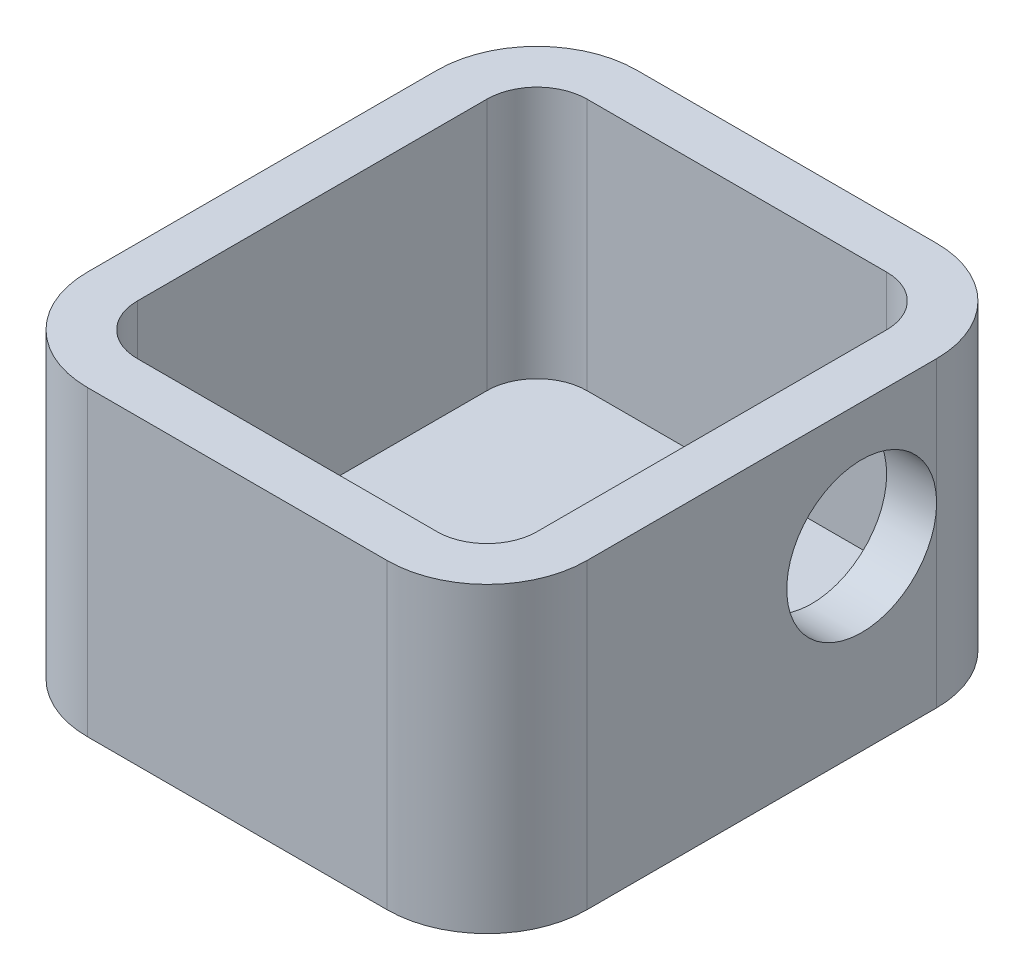
from build123d import *

# Parameters (mm, degrees)
BOSS_EXTRUDE1_DEPTH = 10.11
SKETCH1_3_R         = 4
BOSS_EXTRUDE2_DEPTH = 2
CUT_EXTRUDE1_REACH  = 22
SKETCH3_R           = 3


with BuildPart() as part:
    # Sketch1 → Boss-Extrude1 (new body)
    with BuildSketch(Plane.XZ.offset(5.655564884)):
        with BuildLine():
            Line((-3.830791813, -12.996740626), (-3.830791813, 1.003259374))
            ThreePointArc((-3.830791813, 1.003259374), (-5.002364688, 3.831686499), (-7.830791813, 5.003259374))
            Line((-7.830791813, 5.003259374), (-19.830791813, 5.003259374))
            ThreePointArc((-19.830791813, 5.003259374), (-22.659218938, 3.831686499), (-23.830791813, 1.003259374))
            Line((-23.830791813, 1.003259374), (-23.830791813, -12.996740626))
            ThreePointArc((-23.830791813, -12.996740626), (-22.659218938, -15.825167751), (-19.830791813, -16.996740626))
            Line((-19.830791813, -16.996740626), (-7.830791813, -16.996740626))
            ThreePointArc((-7.830791813, -16.996740626), (-5.002364688, -15.825167751), (-3.830791813, -12.996740626))
        make_face()
        with BuildLine():
            ThreePointArc((-21.830791813, -12.996740626), (-21.245005376, -14.410954188), (-19.830791813, -14.996740626))
            Line((-19.830791813, -14.996740626), (-7.830791813, -14.996740626))
            ThreePointArc((-7.830791813, -14.996740626), (-6.416578251, -14.410954188), (-5.830791813, -12.996740626))
            Line((-5.830791813, -12.996740626), (-5.830791813, 1.003259374))
            ThreePointArc((-5.830791813, 1.003259374), (-6.416578251, 2.417472937), (-7.830791813, 3.003259374))
            Line((-7.830791813, 3.003259374), (-19.830791813, 3.003259374))
            ThreePointArc((-19.830791813, 3.003259374), (-21.245005376, 2.417472937), (-21.830791813, 1.003259374))
            Line((-21.830791813, 1.003259374), (-21.830791813, -12.996740626))
        make_face(mode=Mode.SUBTRACT)
    extrude(amount=-BOSS_EXTRUDE1_DEPTH)

    # Sketch1_3 → Boss-Extrude2 (add)
    with BuildSketch(Plane.XZ.offset(5.655564884)):
        with BuildLine():
            Line((-7.830791813, 5.003259374), (-19.830791813, 5.003259374))
            ThreePointArc((-19.830791813, 5.003259374), (-22.659218938, 3.831686499), (-23.830791813, 1.003259374))
            Line((-23.830791813, 1.003259374), (-23.830791813, -12.996740626))
            ThreePointArc((-23.830791813, -12.996740626), (-22.659218938, -15.825167751), (-19.830791813, -16.996740626))
            Line((-19.830791813, -16.996740626), (-7.830791813, -16.996740626))
            ThreePointArc((-7.830791813, -16.996740626), (-5.002364688, -15.825167751), (-3.830791813, -12.996740626))
            Line((-3.830791813, -12.996740626), (-3.830791813, 1.003259374))
            ThreePointArc((-3.830791813, 1.003259374), (-5.002364688, 3.831686499), (-7.830791813, 5.003259374))
        make_face()
        with Locations((-13.830791813, -1.996740626)):
            Circle(SKETCH1_3_R, mode=Mode.SUBTRACT)
    extrude(amount=BOSS_EXTRUDE2_DEPTH)

    # Sketch3 → Cut-Extrude1 (cut, up to next)
    with BuildSketch(Plane.ZY.offset(3.830791813), mode=Mode.PRIVATE) as cut_extrude1_sk1:
        with Locations((-9.996740626, -0.545564884)):
            Circle(SKETCH3_R)
    cut_extrude1_tool1 = extrude(cut_extrude1_sk1.sketch, amount=CUT_EXTRUDE1_REACH, mode=Mode.PRIVATE) & part.part
    add(cut_extrude1_tool1.solids().sort_by_distance((-3.830792, -0.545565, -9.996741))[0], mode=Mode.SUBTRACT)


solid = part.part
